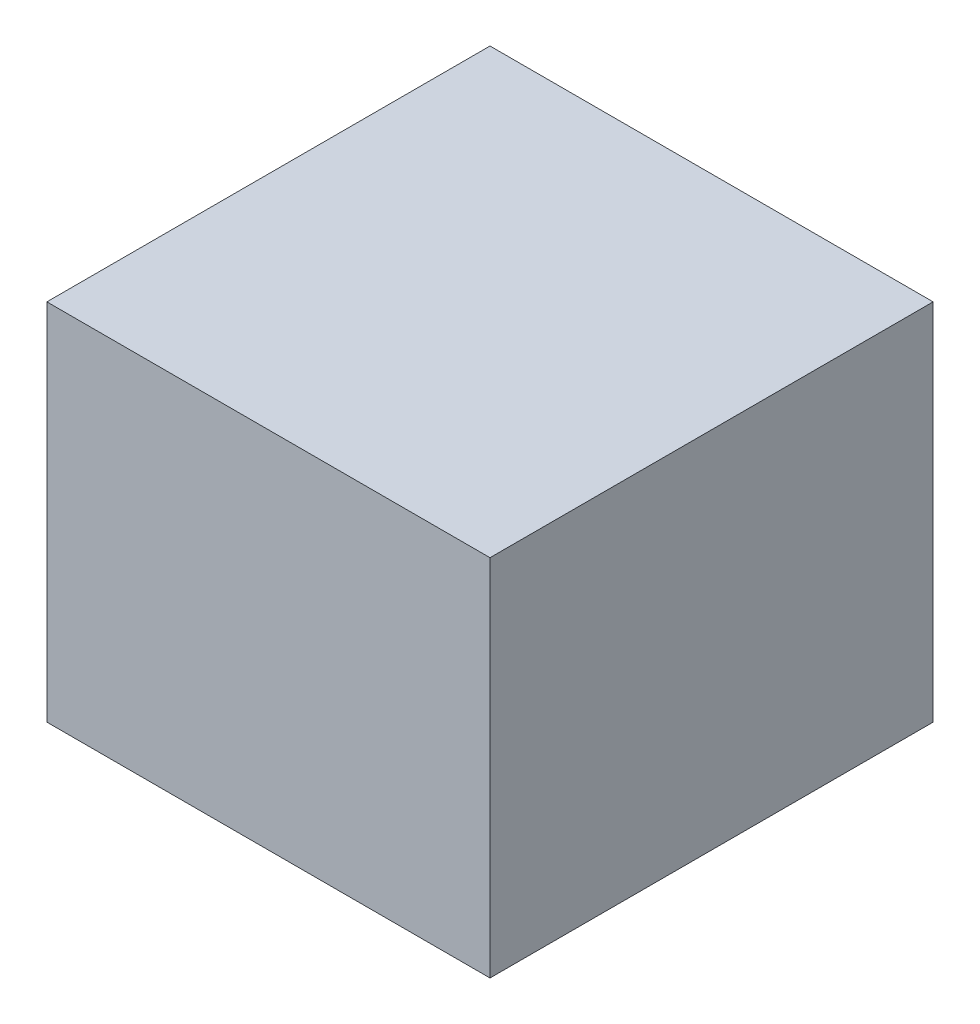
from build123d import *

# Parameters (mm, degrees)
SKETCH1_W           = 140
SKETCH1_H           = 140
BOSS_EXTRUDE1_DEPTH = 115


with BuildPart() as part:
    # Sketch1 → Boss-Extrude1 (new body)
    with BuildSketch(Plane(origin=(0, 0, 0), x_dir=(1, 0, 0), z_dir=(0, 1, 0))):
        Rectangle(SKETCH1_W, SKETCH1_H)
    extrude(amount=BOSS_EXTRUDE1_DEPTH)


solid = part.part
